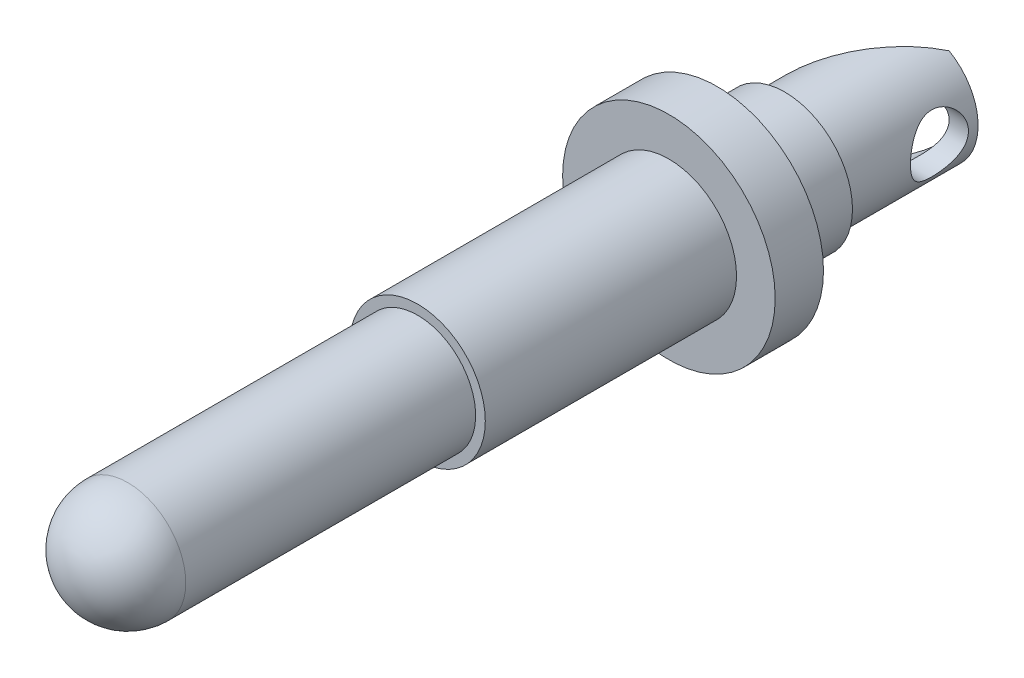
from build123d import *

# Parameters (mm, degrees)
SKETCH_1_R                = 3
EXTRUDE_1_DEPTH           = 15
DOME_1_FACE_RADIUS        = 3
DOME_1_HEIGHT             = 3
SKETCH_4_R                = 3.5
EXTRUDE_2_DEPTH           = 26
SKETCH_5_R                = 3.5
SKETCH_5_R_2              = 3
CUT_EXTRUDE_3_DEPTH       = 7
EXTRUDE_START             = -13
SKETCH_6_R                = 5.5
EXTRUDE_3_DEPTH           = 2.5
HOLE_WIZARD_4_0_4_1_D     = 4
HOLE_WIZARD_4_0_4_1_DEPTH = 7.5
HOLE_WIZARD_4_0_4_1_TIP   = 1.201721238
HOLE_WIZARD_3_0_3_1_D     = 3
HOLE_WIZARD_3_0_3_1_DEPTH = 9
HOLE_WIZARD_3_0_3_1_TIP   = 0.901290929
CUT_EXTRUDE_4_DEPTH       = 6.5
CUT_EXTRUDE_4_DEPTH_BACK  = 6.5


with BuildPart() as part:
    # Sketch 1 → Extrude 1 (new body)
    with BuildSketch(Plane.XY):
        Circle(SKETCH_1_R)
    extrude(amount=EXTRUDE_1_DEPTH)

    # Dome 1: a dome of height H over a round flat face of radius A is a cap of a sphere of radius (A * A + H * H) / (2 * H)
    dome_1_r = (DOME_1_FACE_RADIUS * DOME_1_FACE_RADIUS + DOME_1_HEIGHT * DOME_1_HEIGHT) / (2 * DOME_1_HEIGHT)
    dome_1_base = Plane((0, 0, 15), z_dir=(0, 0, 1))
    with Locations(dome_1_base.offset(DOME_1_HEIGHT - dome_1_r)):
        dome_1_ball = Sphere(dome_1_r, mode=Mode.PRIVATE)
    add(split(dome_1_ball, bisect_by=dome_1_base, keep=Keep.TOP, mode=Mode.PRIVATE))

    # Sketch 4 → Extrude 2 (add)
    with BuildSketch(Plane(origin=(0, 0, 0), x_dir=(-1, 0, 0), z_dir=(0, 0, -1))):
        Circle(SKETCH_4_R)
    extrude(amount=EXTRUDE_2_DEPTH)

    # Sketch 5 → Cut-Extrude 3 (cut)
    with BuildSketch(Plane(origin=(0, 0, -26), x_dir=(-1, 0, 0), z_dir=(0, 0, -1))):
        Circle(SKETCH_5_R)
        Circle(SKETCH_5_R_2, mode=Mode.SUBTRACT)
    extrude(amount=-CUT_EXTRUDE_3_DEPTH, mode=Mode.SUBTRACT)

    # Sketch 6 → Extrude 3 (add)
    with BuildSketch(Plane.XY.offset(EXTRUDE_START)):
        Circle(SKETCH_6_R)
    extrude(amount=-EXTRUDE_3_DEPTH)

    # Hole Wizard 4.0 _4_1
    with Locations(Plane(origin=(0, 0, -26), x_dir=(-1, 0, 0), z_dir=(0, 0, -1))):
        with Locations((0, 0)):
            Hole(HOLE_WIZARD_4_0_4_1_D / 2, depth=HOLE_WIZARD_4_0_4_1_DEPTH)
            with Locations((0, 0, -(HOLE_WIZARD_4_0_4_1_DEPTH + HOLE_WIZARD_4_0_4_1_TIP / 2))):  # 118° drill point
                Cone(0, HOLE_WIZARD_4_0_4_1_D / 2, HOLE_WIZARD_4_0_4_1_TIP, mode=Mode.SUBTRACT)

    # Hole Wizard 3.0 _3_1
    with Locations(Plane(origin=(-3, 0, -24), x_dir=(0, 0, -1), z_dir=(-1, 0, 0))):
        with Locations((0, 0)):
            Hole(HOLE_WIZARD_3_0_3_1_D / 2, depth=HOLE_WIZARD_3_0_3_1_DEPTH)
            with Locations((0, 0, -(HOLE_WIZARD_3_0_3_1_DEPTH + HOLE_WIZARD_3_0_3_1_TIP / 2))):  # 118° drill point
                Cone(0, HOLE_WIZARD_3_0_3_1_D / 2, HOLE_WIZARD_3_0_3_1_TIP, mode=Mode.SUBTRACT)

    # Sketch 12 → Cut-Extrude 4 (cut, two sides)
    with BuildSketch(Plane(origin=(0, 0, 0), x_dir=(1, 0, 0), z_dir=(0, 1, 0))) as cut_extrude_4_sk:
        Polygon((1.5, 26), (-3, 20), (-3, 26), align=None)
    extrude(amount=CUT_EXTRUDE_4_DEPTH, mode=Mode.SUBTRACT)
    extrude(cut_extrude_4_sk.sketch, amount=-CUT_EXTRUDE_4_DEPTH_BACK, mode=Mode.SUBTRACT)


solid = part.part
